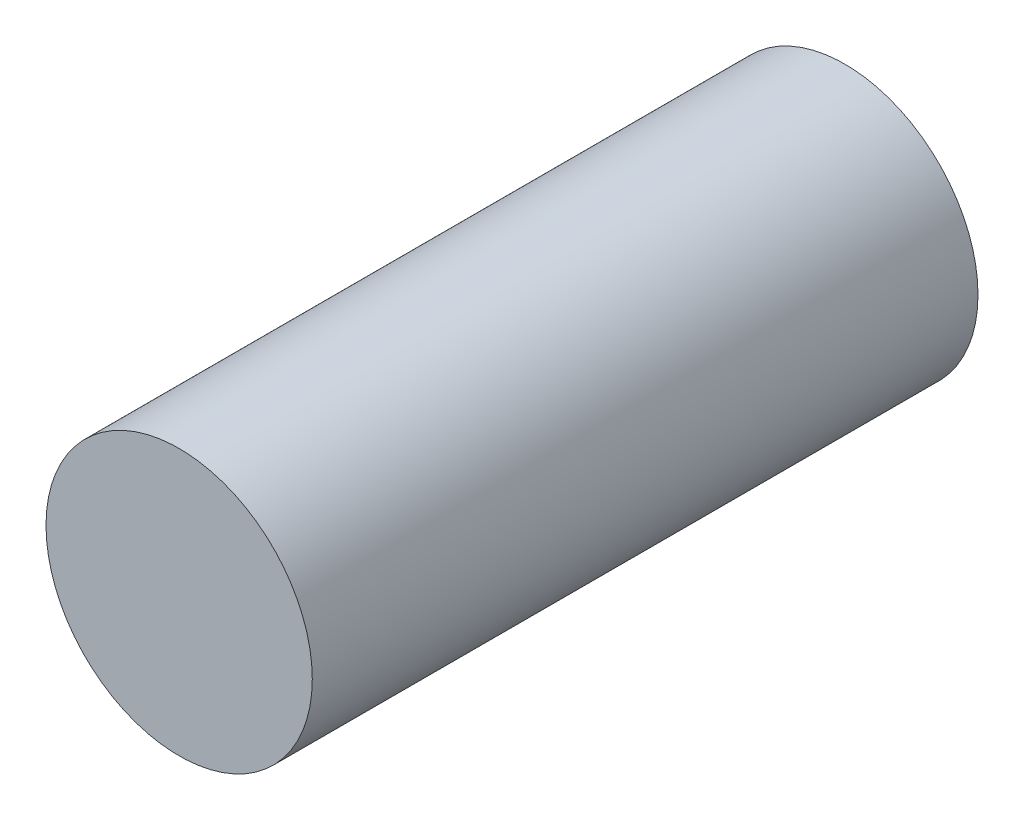
from build123d import *

# Parameters (mm, degrees)
CROQUIS1_R              = 6.35
SALIENTE_EXTRUIR1_DEPTH = 31.75


with BuildPart() as part:
    # Croquis1 → Saliente-Extruir1 (new body)
    with BuildSketch(Plane.XY):
        Circle(CROQUIS1_R)
    extrude(amount=SALIENTE_EXTRUIR1_DEPTH)


solid = part.part
